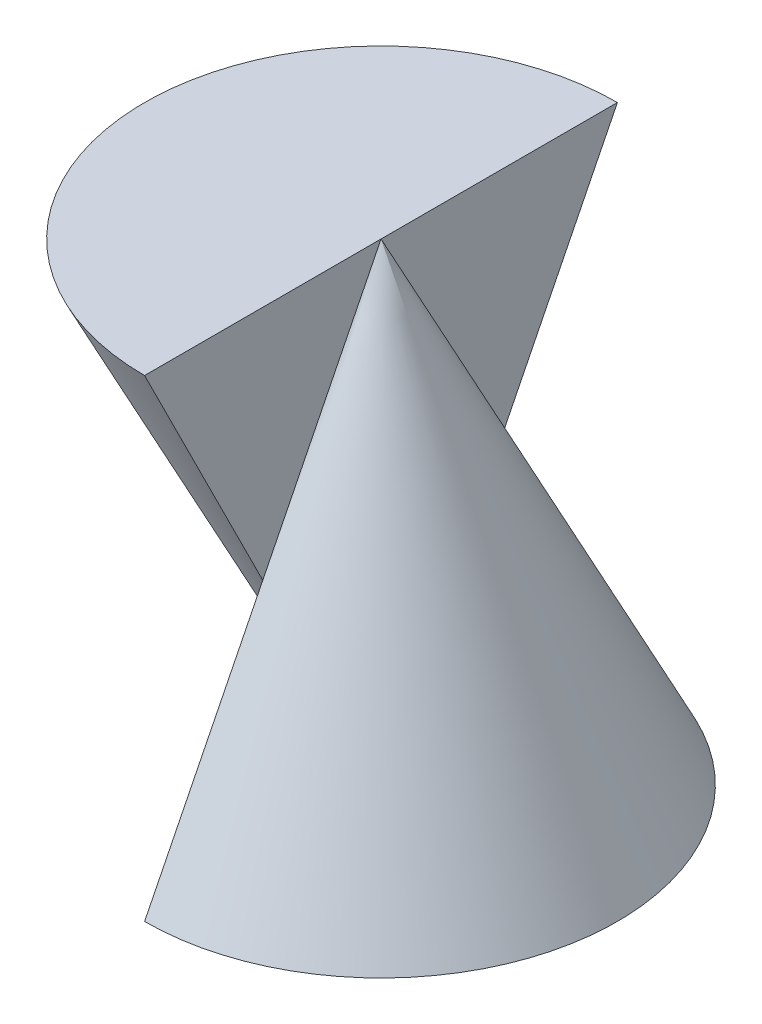
from build123d import *

# Parameters (mm, degrees)
REVOLVE1_ANGLE = 180
REVOLVE2_ANGLE = 180


with BuildPart() as part:
    # Sketch1 → Revolve1 (revolve)
    with BuildSketch(Plane(origin=(0, 0, 0), x_dir=(0, 0, -1), z_dir=(1, 0, 0))):
        Polygon((0, 4), (-2, 0), (0, 0), align=None)
    revolve(axis=Axis((0, 0, 0), (0, 1, 0)), revolution_arc=REVOLVE1_ANGLE)

    # Sketch2 → Revolve2 (revolve)
    with BuildSketch(Plane.ZY):
        Polygon((0, 4), (2, 4), (0, 0), align=None)
    revolve(axis=Axis((0, 0, 0), (0, -1, 0)), revolution_arc=REVOLVE2_ANGLE)


solid = part.part
